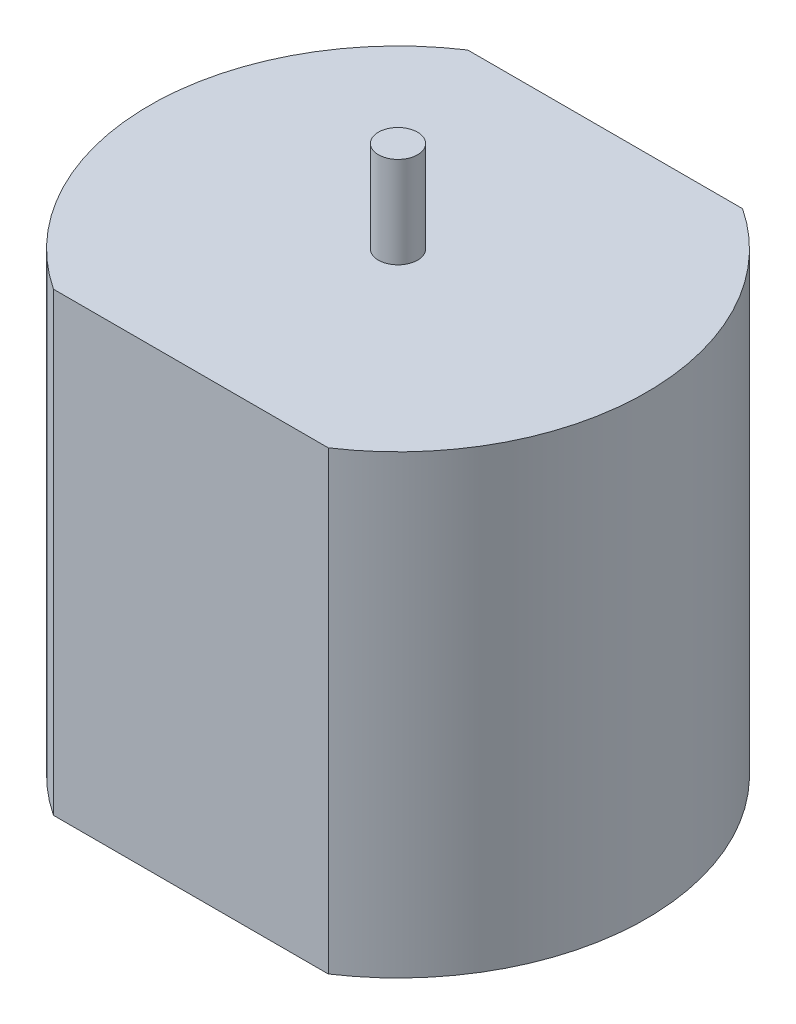
from build123d import *

# Parameters (mm, degrees)
BOSS_EXTRUDE1_DEPTH = 6.35
BOSS_EXTRUDE2_DEPTH = 11.1125
SKETCH3_R           = 0.75
BOSS_EXTRUDE3_DEPTH = 3.5


with BuildPart() as part:
    # Sketch1 → Boss-Extrude1 (new body)
    with BuildSketch(Plane(origin=(0, 0, 0), x_dir=(1, 0, 0), z_dir=(0, 1, 0))):
        with BuildLine():
            Line((5.265141855, 7.9375), (-5.265141855, 7.9375))
            ThreePointArc((-5.265141855, 7.9375), (-9.525, 0), (-5.265141855, -7.9375))
            Line((-5.265141855, -7.9375), (5.265141855, -7.9375))
            ThreePointArc((5.265141855, -7.9375), (9.525, 0), (5.265141855, 7.9375))
        make_face()
    extrude(amount=BOSS_EXTRUDE1_DEPTH)

    # Sketch2 → Boss-Extrude2 (add)
    with BuildSketch(Plane(origin=(0, 6.35, 0), x_dir=(1, 0, 0), z_dir=(0, 1, 0))):
        with BuildLine():
            Line((5.265141855, 7.9375), (-5.265141855, 7.9375))
            ThreePointArc((-5.265141855, 7.9375), (-9.525, 0), (-5.265141855, -7.9375))
            Line((-5.265141855, -7.9375), (5.265141855, -7.9375))
            ThreePointArc((5.265141855, -7.9375), (9.525, 0), (5.265141855, 7.9375))
        make_face()
    extrude(amount=BOSS_EXTRUDE2_DEPTH)

    # Sketch3 → Boss-Extrude3 (add)
    with BuildSketch(Plane(origin=(0, 17.4625, 0), x_dir=(1, 0, 0), z_dir=(0, 1, 0))):
        Circle(SKETCH3_R)
    extrude(amount=BOSS_EXTRUDE3_DEPTH)


solid = part.part
